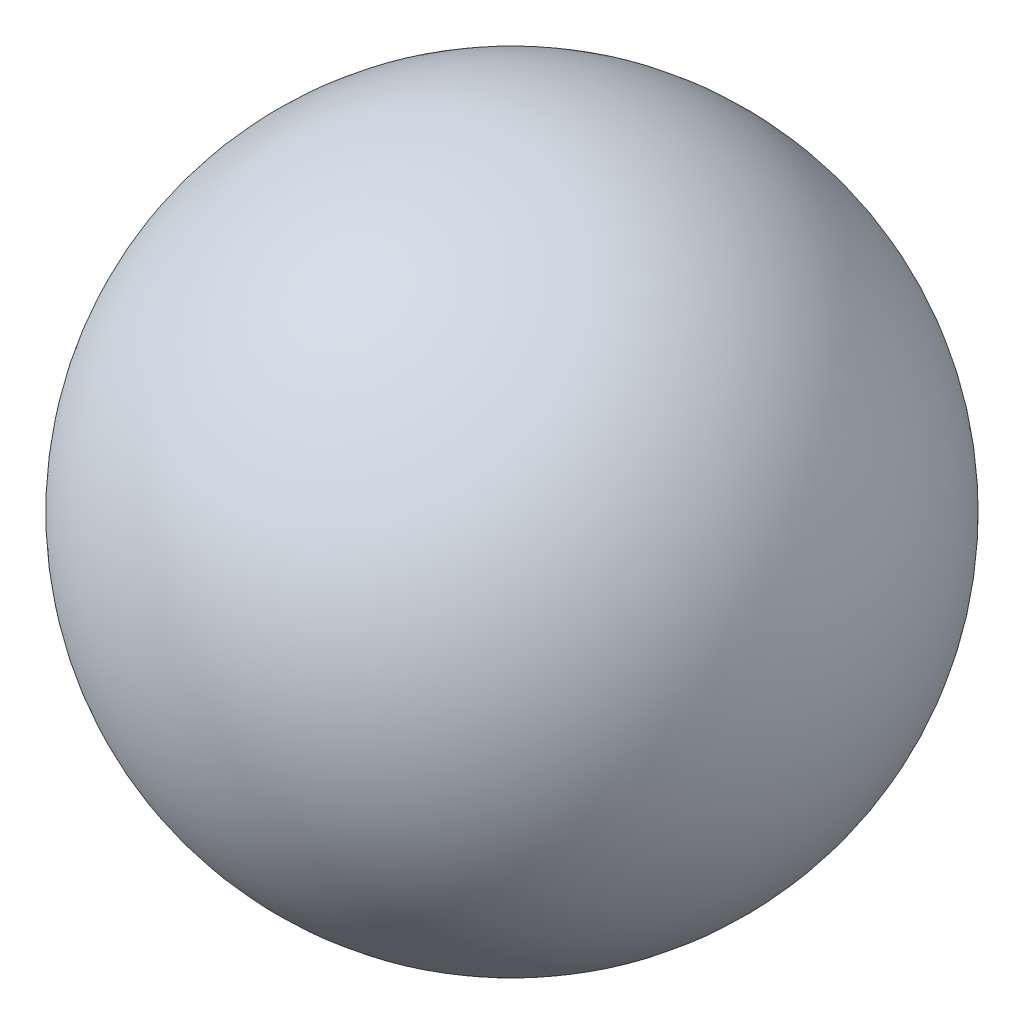
from build123d import *


with BuildPart() as part:
    # Esquisse1 → R_volution1 (revolve)
    with BuildSketch(Plane(origin=(0, 0, 0), x_dir=(-1, 0, 0), z_dir=(0, 0, -1))):
        with BuildLine():
            Line((0, 8.25), (0, 5.25))
            ThreePointArc((0, 5.25), (-1.5, 6.75), (0, 8.25))
        make_face()
    revolve(axis=Axis((0, 0, 0), (0, 1, 0)))


solid = part.part
